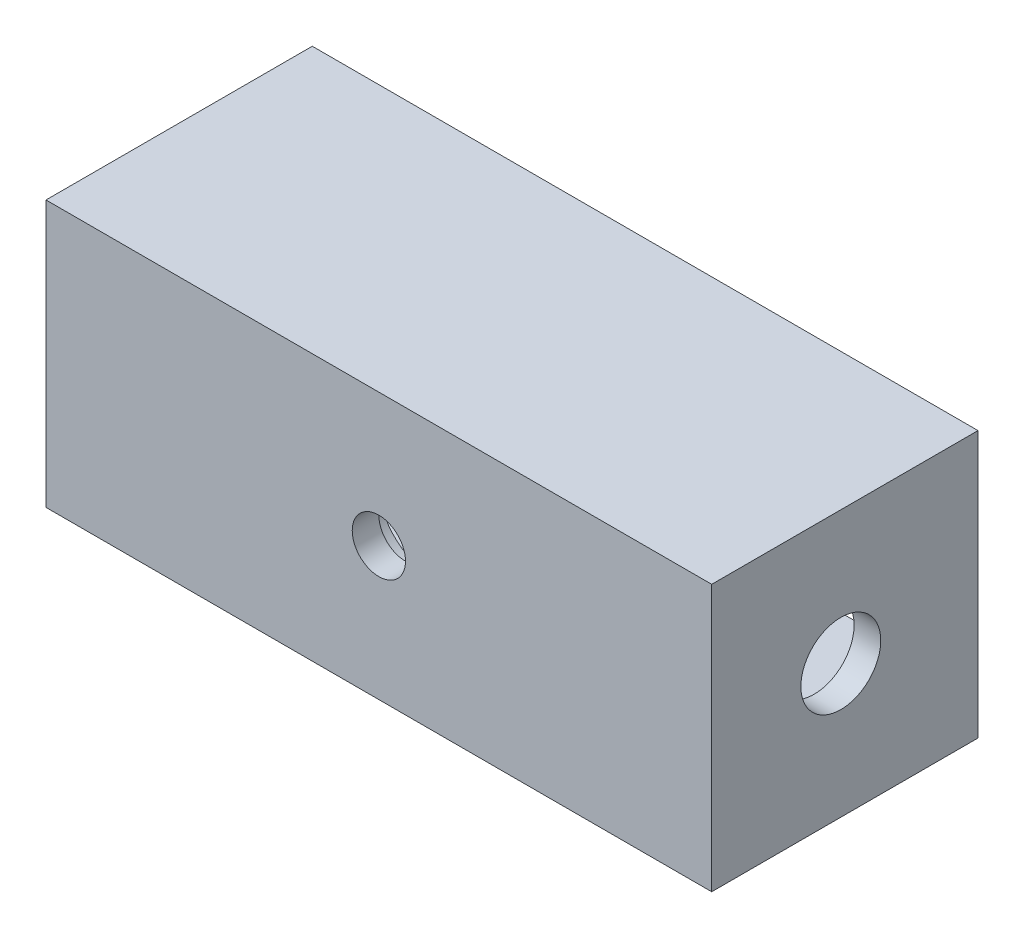
from build123d import *

# Parameters (mm, degrees)
SKETCH1_W           = 25
SKETCH1_H           = 10
BOSS_EXTRUDE1_DEPTH = 10
SKETCH2_W           = 23
SKETCH2_H           = 7
CUT_EXTRUDE1_DEPTH  = 8
SKETCH3_R           = 1.5
CUT_EXTRUDE2_DEPTH  = 51
SKETCH4_R           = 2
CUT_EXTRUDE3_DEPTH  = 1
SKETCH5_R           = 1
CUT_EXTRUDE4_DEPTH  = 4


with BuildPart() as part:
    # Sketch1 → Boss-Extrude1 (new body)
    with BuildSketch(Plane.XY):
        Rectangle(SKETCH1_W, SKETCH1_H)
    extrude(amount=BOSS_EXTRUDE1_DEPTH)

    # Sketch2 → Cut-Extrude1 (cut)
    with BuildSketch(Plane(origin=(0, 0, 0), x_dir=(-1, 0, 0), z_dir=(0, 0, -1))):
        Rectangle(SKETCH2_W, SKETCH2_H)
    extrude(amount=-CUT_EXTRUDE1_DEPTH, mode=Mode.SUBTRACT)

    # Sketch3 → Cut-Extrude2 (cut)
    with BuildSketch(Plane(origin=(12.5, 0, 0), x_dir=(0, 0, -1), z_dir=(1, 0, 0))):
        with Locations((-5.152207195, 0)):
            Circle(SKETCH3_R)
    extrude(amount=-CUT_EXTRUDE2_DEPTH, mode=Mode.SUBTRACT)

    # Sketch4 → Cut-Extrude3 (cut)
    with BuildSketch(Plane(origin=(0, 0, 8), x_dir=(-1, 0, 0), z_dir=(0, 0, -1))):
        Circle(SKETCH4_R)
    extrude(amount=-CUT_EXTRUDE3_DEPTH, mode=Mode.SUBTRACT)

    # Sketch5 → Cut-Extrude4 (cut)
    with BuildSketch(Plane(origin=(0, 0, 9), x_dir=(-1, 0, 0), z_dir=(0, 0, -1))):
        Circle(SKETCH5_R)
    extrude(amount=-CUT_EXTRUDE4_DEPTH, mode=Mode.SUBTRACT)


solid = part.part
